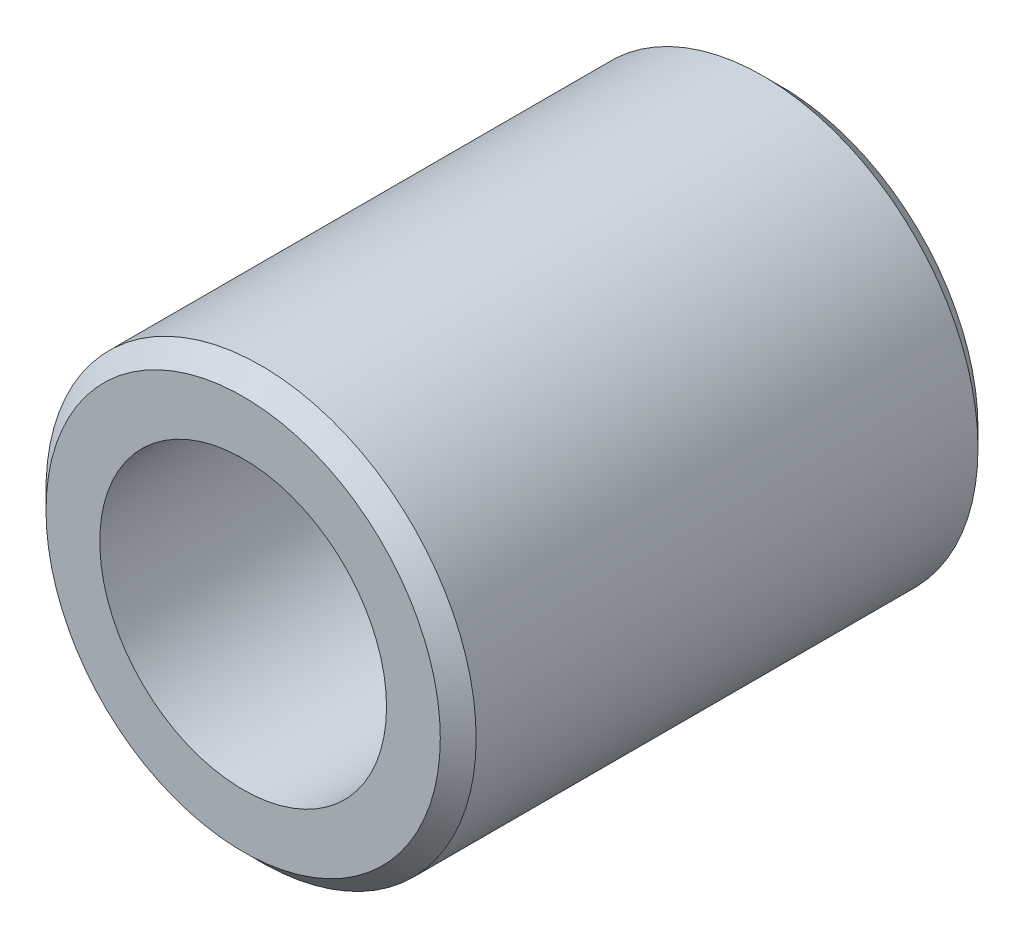
from build123d import *

# Parameters (mm, degrees)
SKETCH1_R           = 6
SKETCH1_R_2         = 4
EXTRUDE_THIN1_DEPTH = 15
CHAMFER1_SIZE       = 0.5


with BuildPart() as part:
    # Sketch1 → Extrude-Thin1 (new body)
    with BuildSketch(Plane.XY):
        Circle(SKETCH1_R)
        Circle(SKETCH1_R_2, mode=Mode.SUBTRACT)
    extrude(amount=EXTRUDE_THIN1_DEPTH)

    # Chamfer1
    chamfer1_edges = [part.edges().sort_by_distance(p)[0] for p in [
        (-6, 0, 0),
        (-6, 0, 15),
    ]]
    chamfer(chamfer1_edges, length=CHAMFER1_SIZE)


solid = part.part
